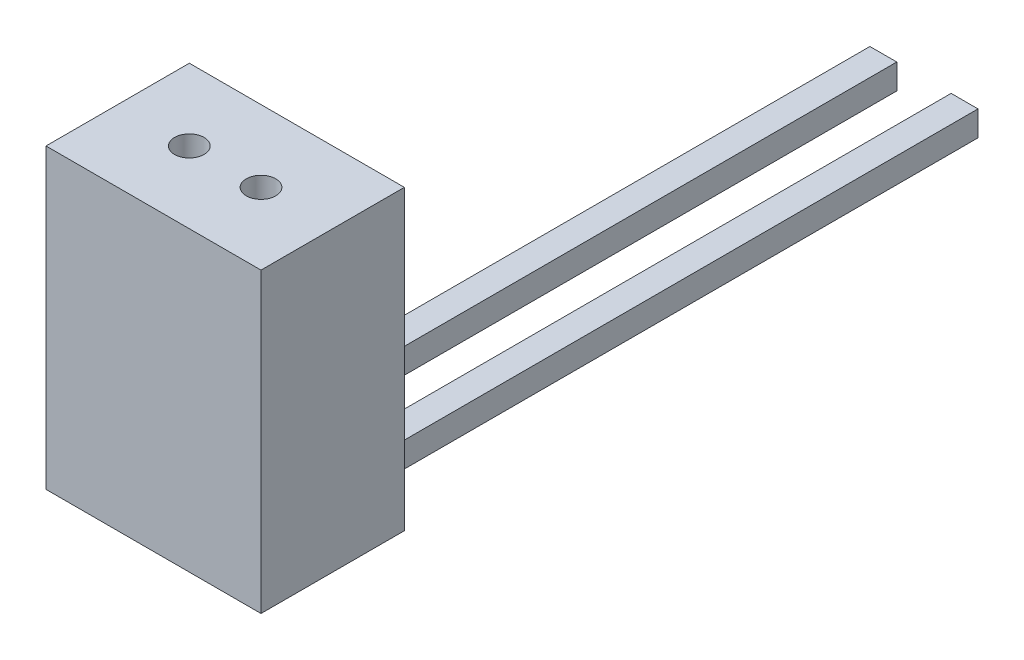
from build123d import *

# Parameters (mm, degrees)
SKETCH2_W             = 3
SKETCH2_H             = 2.8
BOSS_EXTRUDE1_DEPTH   = 70
BOSS_EXTRUDE1_2_DEPTH = 70
SKETCH3_W             = 24
SKETCH3_H             = 33.2
BOSS_EXTRUDE2_DEPTH   = 16
SKETCH4_R             = 1.65
CUT_EXTRUDE1_DEPTH    = 34.2
CUT_EXTRUDE2_START    = 3
CUT_EXTRUDE2_DEPTH    = 2.8


with BuildPart() as part:
    # Sketch2 → Boss-Extrude1 (new body)
    with BuildSketch(Plane.XY):
        with Locations((7.466666667, 1.4)):
            Rectangle(SKETCH2_W, SKETCH2_H)
    extrude(amount=-BOSS_EXTRUDE1_DEPTH)



with BuildPart() as body_2:
    # Sketch2 → Boss-Extrude1 2 (new body)
    with BuildSketch(Plane.XY):
        with Locations((16.533333333, 1.4)):
            Rectangle(SKETCH2_W, SKETCH2_H)
    extrude(amount=-BOSS_EXTRUDE1_2_DEPTH)


with BuildPart() as part_1:
    add(part.part)

    add(body_2.part)  # Boss-Extrude2 merges body 2
    # Sketch3 → Boss-Extrude2 (add)
    with BuildSketch(Plane.XY):
        with Locations((12, 16.6)):
            Rectangle(SKETCH3_W, SKETCH3_H)
    extrude(amount=BOSS_EXTRUDE2_DEPTH)

    # Sketch4 → Cut-Extrude1 (cut, through all)
    with BuildSketch(Plane(origin=(0, 0, 0), x_dir=(1, 0, 0), z_dir=(0, 1, 0))):
        with Locations((8, -8)):
            Circle(SKETCH4_R)
        with Locations((16, -8)):
            Circle(SKETCH4_R)
    extrude(amount=CUT_EXTRUDE1_DEPTH, mode=Mode.SUBTRACT)

    # Sketch5 → Cut-Extrude2 (cut)
    with BuildSketch(Plane(origin=(0, 0, 0), x_dir=(1, 0, 0), z_dir=(0, 1, 0)).offset(CUT_EXTRUDE2_START)):
        Polygon((11.290896534, -8), (9.645448267, -5.15), (6.354551733, -5.15), (4.709103466, -8), (6.354551733, -10.85), (9.645448267, -10.85), align=None)
        Polygon((19.290896534, -8), (17.645448267, -5.15), (14.354551733, -5.15), (12.709103466, -8), (14.354551733, -10.85), (17.645448267, -10.85), align=None)
    extrude(amount=CUT_EXTRUDE2_DEPTH, mode=Mode.SUBTRACT)


solid = part_1.part
